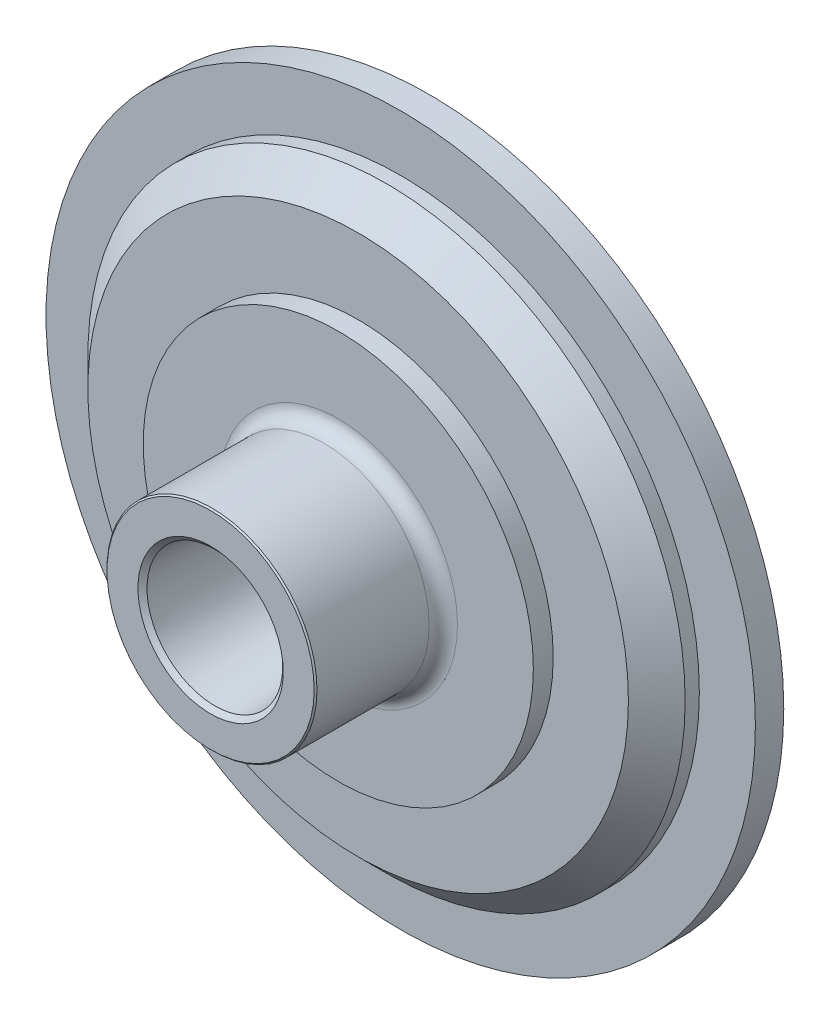
from build123d import *


with BuildPart() as part:
    # Эскиз1 → Повернуть2 (revolve)
    with BuildSketch(Plane(origin=(0, 0, 0), x_dir=(0, 0, -1), z_dir=(1, 0, 0))):
        with BuildLine():
            Line((65.481855233, 20.76), (15.978837376, 23.904897605))
            Line((15.978837376, 23.904897605), (14.481855233, 25.604987877))
            Line((14.481855233, 25.604987877), (14.481855233, 36.5))
            Line((14.481855233, 36.5), (14.981855233, 37))
            Line((14.981855233, 37), (54.481855233, 37))
            ThreePointArc((54.481855233, 37), (58.017389139, 38.464466094), (59.481855233, 42))
            Line((59.481855233, 42), (59.481855233, 68.75))
            Line((59.481855233, 68.75), (66.481855233, 68.75))
            Line((66.481855233, 68.75), (66.481855233, 95.25))
            Line((66.481855233, 95.25), (76.481855233, 105.25))
            Line((76.481855233, 105.25), (81.481855233, 105.25))
            Line((81.481855233, 105.25), (81.481855233, 125))
            Line((81.481855233, 125), (91.481855233, 125))
            Line((91.481855233, 125), (91.481855233, 95))
            Line((91.481855233, 95), (94.481855233, 95))
            Line((94.481855233, 95), (94.481855233, 90))
            Line((94.481855233, 90), (79.481855233, 90))
            Line((79.481855233, 90), (79.481855233, 66.15))
            Line((79.481855233, 66.15), (75.981855233, 66.15))
            Line((75.981855233, 66.15), (75.981855233, 53.186533479))
            Line((75.981855233, 53.186533479), (65.481855233, 35))
            Line((65.481855233, 35), (65.481855233, 20.76))
        make_face()
    revolve(axis=Axis((0, 0, -5.281550862), (0, 0, -1)))


solid = part.part
